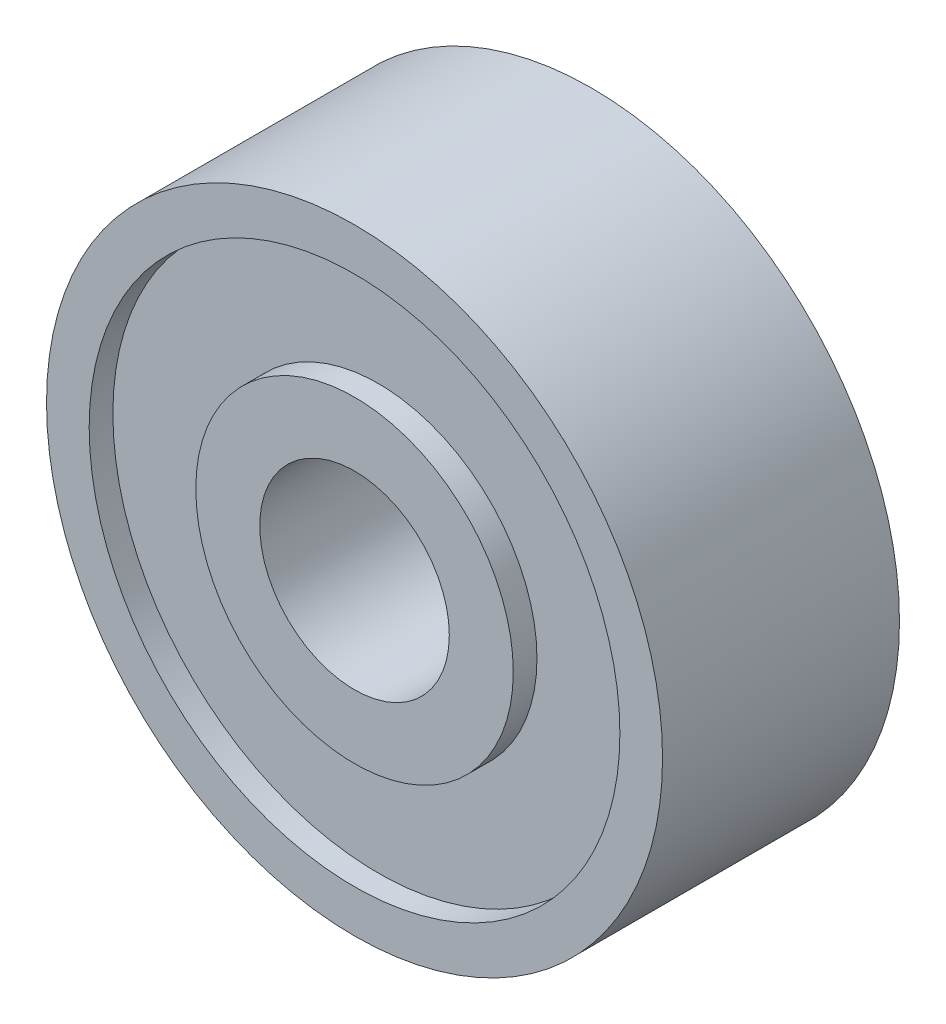
from build123d import *

# Parameters (mm, degrees)
SKETCH_1_R          = 6.5
EXTRUDE_1_DEPTH     = 5
SKETCH_2_R          = 2
CUT_EXTRUDE_1_DEPTH = 6
SKETCH_3_R          = 5.6
SKETCH_3_R_2        = 3.35
CUT_EXTRUDE_2_DEPTH = 0.5
SKETCH_4_R          = 5.6
SKETCH_4_R_2        = 3.35
CUT_EXTRUDE_3_DEPTH = 0.5


with BuildPart() as part:
    # 草圖1 → 填料-伸長1 (new body)
    with BuildSketch(Plane.XY):
        Circle(SKETCH_1_R)
    extrude(amount=EXTRUDE_1_DEPTH)

    # 草圖2 → 除料-伸長1 (cut, through all)
    with BuildSketch(Plane.XY.offset(5)):
        Circle(SKETCH_2_R)
    extrude(amount=-CUT_EXTRUDE_1_DEPTH, mode=Mode.SUBTRACT)

    # 草圖3 → 除料-伸長2 (cut)
    with BuildSketch(Plane.XY.offset(5)):
        Circle(SKETCH_3_R)
        Circle(SKETCH_3_R_2, mode=Mode.SUBTRACT)
    extrude(amount=-CUT_EXTRUDE_2_DEPTH, mode=Mode.SUBTRACT)

    # 草圖4 → 除料-伸長3 (cut)
    with BuildSketch(Plane(origin=(0, 0, 0), x_dir=(-1, 0, 0), z_dir=(0, 0, -1))):
        Circle(SKETCH_4_R)
        Circle(SKETCH_4_R_2, mode=Mode.SUBTRACT)
    extrude(amount=-CUT_EXTRUDE_3_DEPTH, mode=Mode.SUBTRACT)


solid = part.part
